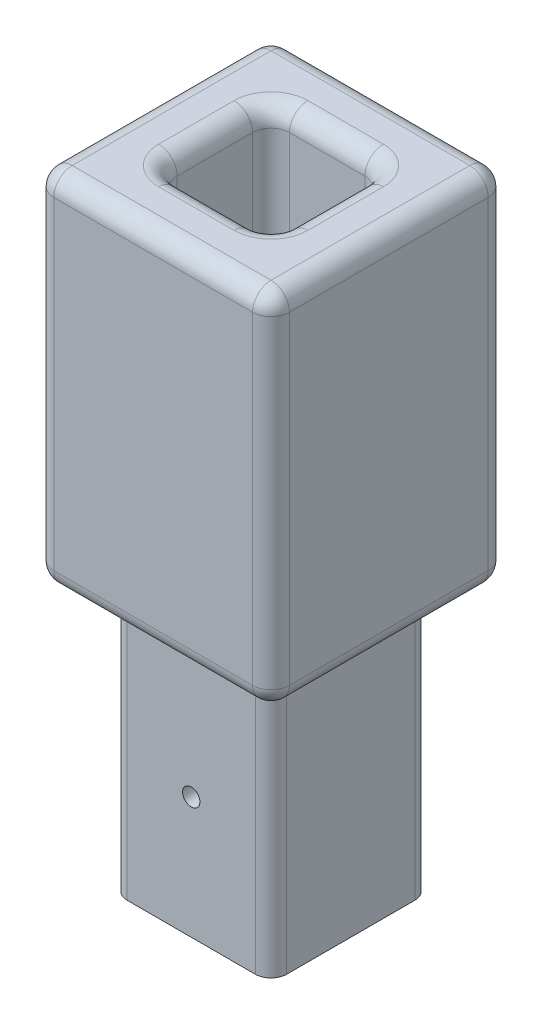
from build123d import *

# Parameters (mm, degrees)
SKETCH1_W           = 25.781
SKETCH1_H           = 25.781
SKETCH1_W_2         = 18.161
SKETCH1_H_2         = 18.161
BOSS_EXTRUDE1_DEPTH = 101.6
BOSS_EXTRUDE2_START = 43.4
SKETCH1_3_W         = 38.1
SKETCH1_3_H         = 38.1
SKETCH1_3_W_2       = 25.781
SKETCH1_3_H_2       = 25.781
BOSS_EXTRUDE2_DEPTH = 58.2
FILLET1_R           = 2.54
FILLET2_R           = 2.9845
SKETCH2_R           = 1.4
CUT_EXTRUDE1_DEPTH  = 37.592


with BuildPart() as part:
    # Sketch1 → Boss-Extrude1 (new body)
    with BuildSketch(Plane(origin=(0, 0, 0), x_dir=(1, 0, 0), z_dir=(0, 1, 0))):
        Rectangle(SKETCH1_W, SKETCH1_H)
        Rectangle(SKETCH1_W_2, SKETCH1_H_2, mode=Mode.SUBTRACT)
    extrude(amount=BOSS_EXTRUDE1_DEPTH)

    # Sketch1_3 → Boss-Extrude2 (add)
    with BuildSketch(Plane(origin=(0, 0, 0), x_dir=(1, 0, 0), z_dir=(0, 1, 0)).offset(BOSS_EXTRUDE2_START)):
        Rectangle(SKETCH1_3_W, SKETCH1_3_H)
        Rectangle(SKETCH1_3_W_2, SKETCH1_3_H_2, mode=Mode.SUBTRACT)
    extrude(amount=BOSS_EXTRUDE2_DEPTH)

    # Fillet1
    fillet1_edges = [part.edges().sort_by_distance(p)[0] for p in [
        (-12.8905, 21.7, -12.8905),
        (12.8905, 21.7, -12.8905),
        (12.8905, 21.7, 12.8905),
        (-12.8905, 21.7, 12.8905),
    ]]
    fillet(fillet1_edges, radius=FILLET1_R)

    # Fillet2
    fillet2_edges = [part.edges().sort_by_distance(p)[0] for p in [
        (0, 0, 9.0805),
        (9.0805, 0, 0),
        (9.0805, 50.8, -9.0805),
        (-9.0805, 50.8, -9.0805),
        (-9.0805, 50.8, 9.0805),
        (9.0805, 50.8, 9.0805),
        (9.0805, 101.6, 0),
        (0, 101.6, 9.0805),
        (19.05, 72.5, -19.05),
        (0, 43.4, -19.05),
        (19.05, 72.5, 19.05),
        (19.05, 43.4, 0),
        (0, 101.6, 19.05),
        (-19.05, 72.5, 19.05),
        (-19.05, 101.6, 0),
        (-19.05, 72.5, -19.05),
        (-9.0805, 101.6, 0),
        (-19.05, 43.4, 0),
        (0, 43.4, 19.05),
        (19.05, 101.6, 0),
        (0, 101.6, -19.05),
        (0, 101.6, -9.0805),
        (0, 0, -9.0805),
        (-9.0805, 0, 0),
    ]]
    fillet(fillet2_edges, radius=FILLET2_R)

    # Sketch2 → Cut-Extrude1 (cut)
    with BuildSketch(Plane(origin=(0, 0, -12.8905), x_dir=(-1, 0, 0), z_dir=(0, 0, -1))):
        with Locations((0, 19.643054378)):
            Circle(SKETCH2_R)
    extrude(amount=-CUT_EXTRUDE1_DEPTH, mode=Mode.SUBTRACT)


solid = part.part
